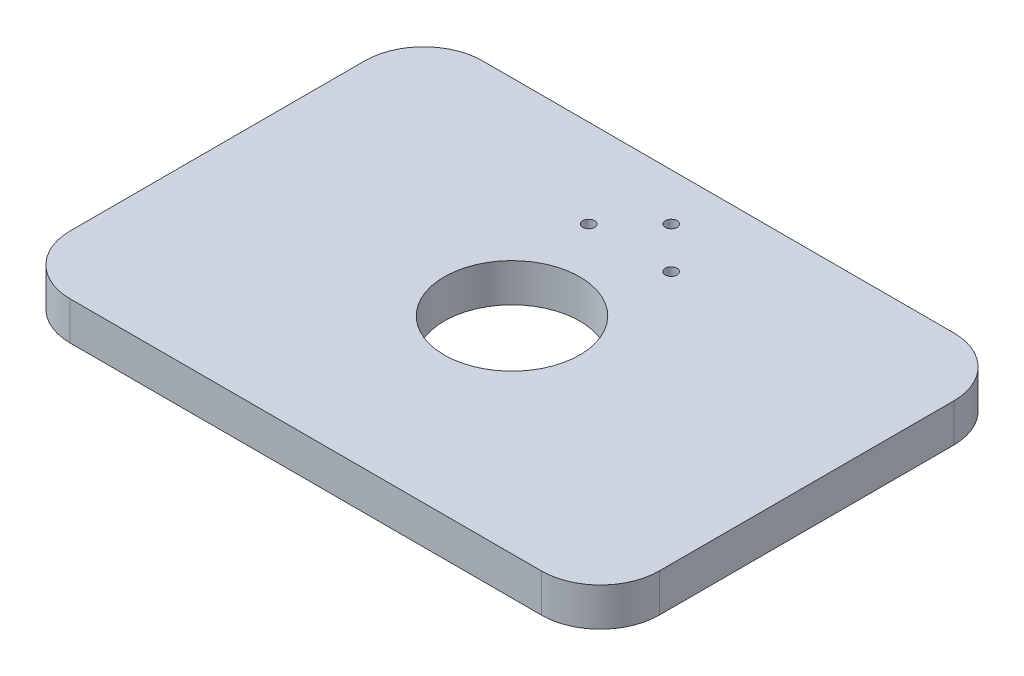
from build123d import *

# Parameters (mm, degrees)
SKETCH1_W           = 100
SKETCH1_H           = 70
BOSS_EXTRUDE1_DEPTH = 6.5
SKETCH2_R           = 11.5
CUT_EXTRUDE1_DEPTH  = 19
CUT_EXTRUDE2_DEPTH  = 8
FILLET1_R           = 10


with BuildPart() as part:
    # Sketch1 → Boss-Extrude1 (new body)
    with BuildSketch(Plane(origin=(0, 0, 0), x_dir=(1, 0, 0), z_dir=(0, 1, 0))):
        Rectangle(SKETCH1_W, SKETCH1_H)
    extrude(amount=BOSS_EXTRUDE1_DEPTH)

    # Sketch2 → Cut-Extrude1 (cut)
    with BuildSketch(Plane(origin=(10.212212675, 6.5, 1.842409503), x_dir=(1, 0, 0), z_dir=(0, 1, 0))):
        with Locations((-10.212212675, 1.842409503)):
            Circle(SKETCH2_R)
    extrude(amount=-CUT_EXTRUDE1_DEPTH, mode=Mode.SUBTRACT)

    # Sketch3 → Cut-Extrude2 (cut)
    with BuildSketch(Plane(origin=(10.212212675, 6.5, 1.842409503), x_dir=(1, 0, 0), z_dir=(0, -1, 0))):
        with BuildLine():
            ThreePointArc((-17.21221269, -20.872409503), (-18.202212675, -21.862409519), (-17.212212659, -22.852409503))
            ThreePointArc((-17.212212659, -22.852409503), (-16.222212675, -21.862409488), (-17.21221269, -20.872409503))
        make_face()
        with BuildLine():
            ThreePointArc((-10.212212691, -27.862409503), (-11.212212675, -28.86240952), (-10.212212658, -29.862409503))
            ThreePointArc((-10.212212658, -29.862409503), (-9.212212675, -28.862409487), (-10.212212691, -27.862409503))
        make_face()
        with BuildLine():
            ThreePointArc((-3.212212691, -20.862409503), (-4.212212675, -21.86240952), (-3.212212658, -22.862409503))
            ThreePointArc((-3.212212658, -22.862409503), (-2.212212675, -21.862409487), (-3.212212691, -20.862409503))
        make_face()
    extrude(amount=CUT_EXTRUDE2_DEPTH, mode=Mode.SUBTRACT)

    # Fillet1
    fillet1_edges = [part.edges().sort_by_distance(p)[0] for p in [
        (-50, 3.25, -35),
        (50, 3.25, -35),
        (50, 3.25, 35),
        (-50, 3.25, 35),
    ]]
    fillet(fillet1_edges, radius=FILLET1_R)


solid = part.part
